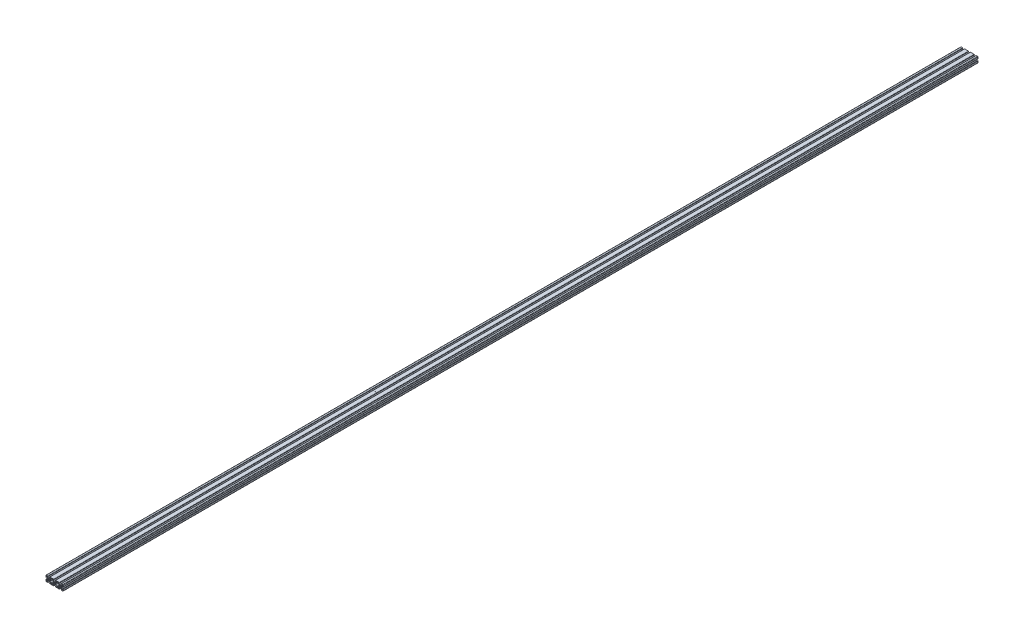
from build123d import *

# Parameters (mm, degrees)
SKETCH2_R      = 2.5
SKETCH2_R_2    = 2.500000001
EXTRUDE1_DEPTH = 4000


with BuildPart() as part:
    # Sketch2 → Extrude1 (new body)
    with BuildSketch(Plane.XY):
        with BuildLine():
            Line((-29.319999998, -10.360000001), (-31.428177133, -10.360000001))
            ThreePointArc((-31.428177133, -10.360000001), (-32.353740777, -9.741558146), (-32.136572877, -8.649781388))
            Line((-32.136572877, -8.649781388), (-29.108786522, -5.621995032))
            ThreePointArc((-29.108786522, -5.621995032), (-28.001435275, -4.721873879), (-26.611168365, -4.399999999))
            Line((-26.611168365, -4.399999999), (-23.423540193, -4.399999999))
            ThreePointArc((-23.423540193, -4.399999999), (-22.212951572, -4.640801047), (-21.186664095, -5.326544416))
            Line((-21.186664095, -5.326544416), (-17.863427125, -8.649781386))
            ThreePointArc((-17.863427125, -8.649781386), (-17.646259225, -9.741558144), (-18.571822869, -10.359999999))
            Line((-18.571822869, -10.359999999), (-20.680000002, -10.360000001))
            ThreePointArc((-20.680000002, -10.360000001), (-21.750000002, -11.430000001), (-20.680000002, -12.500000001))
            Line((-20.680000002, -12.500000001), (-4.320000002, -12.500000001))
            ThreePointArc((-4.320000002, -12.500000001), (-3.24968693, -11.403479825), (-4.371772704, -10.360000029))
            Line((-4.371772704, -10.360000001), (-6.428177131, -10.360000001))
            ThreePointArc((-6.428177131, -10.360000001), (-7.353740776, -9.741558146), (-7.136572876, -8.649781386))
            Line((-7.136572876, -8.649781386), (-3.813335906, -5.326544416))
            ThreePointArc((-3.813335906, -5.326544416), (-2.787048429, -4.640801048), (-1.576459809, -4.399999999))
            Line((-1.576459809, -4.399999999), (1.576459809, -4.399999999))
            ThreePointArc((1.576459809, -4.399999999), (2.787048429, -4.640801048), (3.813335906, -5.326544416))
            Line((3.813335906, -5.326544416), (7.136572876, -8.649781386))
            ThreePointArc((7.136572876, -8.649781386), (7.353740776, -9.741558146), (6.428177131, -10.360000001))
            Line((6.428177131, -10.360000001), (4.371772496, -10.360000001))
            ThreePointArc((4.371772496, -10.360000019), (3.249686927, -11.403479929), (4.320000002, -12.500000001))
            Line((4.320000002, -12.500000001), (20.671857829, -12.500000001))
            ThreePointArc((20.671857829, -12.500000001), (21.745921199, -11.32816463), (20.485180343, -10.359999998))
            Line((20.485180343, -10.359999998), (18.571822869, -10.359999999))
            ThreePointArc((18.571822869, -10.359999999), (17.646259225, -9.741558144), (17.863427125, -8.649781386))
            Line((17.863427125, -8.649781386), (21.186664094, -5.326544417))
            ThreePointArc((21.186664094, -5.326544417), (22.212951571, -4.640801048), (23.423540191, -4.4))
            Line((23.423540191, -4.4), (26.576459807, -4.4))
            ThreePointArc((26.576459807, -4.4), (27.787048427, -4.640801048), (28.813335904, -5.326544417))
            Line((28.813335904, -5.326544417), (32.136572872, -8.649781385))
            ThreePointArc((32.136572872, -8.649781385), (32.353740772, -9.741558143), (31.428177128, -10.359999998))
            Line((31.428177128, -10.359999998), (29.514819652, -10.359999998))
            ThreePointArc((29.514819652, -10.359999998), (28.254078799, -11.328164632), (29.32814217, -12.500000001))
            Line((29.32814217, -12.500000001), (35.535224212, -12.500000001))
            ThreePointArc((35.535224212, -12.500000001), (36.924530495, -11.924530496), (37.5, -10.535224214))
            Line((37.5, -10.535224214), (37.5, -4.32))
            ThreePointArc((37.5, -4.32), (36.43, -3.25), (35.36, -4.32))
            Line((35.36, -4.32), (35.36, -6.428177131))
            ThreePointArc((35.36, -6.428177131), (34.741558145, -7.353740775), (33.649781387, -7.136572875))
            Line((33.649781387, -7.136572875), (30.326544417, -3.813335905))
            ThreePointArc((30.326544417, -3.813335905), (29.640801048, -2.787048428), (29.4, -1.576459808))
            Line((29.4, -1.576459808), (29.4, 1.576459808))
            ThreePointArc((29.4, 1.576459808), (29.640801048, 2.787048428), (30.326544417, 3.813335905))
            Line((30.326544417, 3.813335905), (33.649781387, 7.136572875))
            ThreePointArc((33.649781387, 7.136572875), (34.741558145, 7.353740775), (35.36, 6.428177131))
            Line((35.36, 6.428177131), (35.36, 4.32))
            ThreePointArc((35.36, 4.32), (36.43, 3.25), (37.5, 4.32))
            Line((37.5, 4.32), (37.5, 9.215385711))
            Line((37.5, 9.215385711), (37.5, 10.535224213))
            ThreePointArc((37.5, 10.535224213), (36.924530495, 11.924530496), (35.535224212, 12.500000001))
            Line((35.535224212, 12.500000001), (29.514819654, 12.500000001))
            ThreePointArc((29.514819654, 12.500000001), (28.444819654, 11.430000001), (29.514819654, 10.360000001))
            Line((29.514819654, 10.360000001), (31.42817713, 10.360000001))
            ThreePointArc((31.42817713, 10.360000001), (32.353740774, 9.741558146), (32.136572875, 8.649781388))
            Line((32.136572875, 8.649781388), (28.813335904, 5.326544418))
            ThreePointArc((28.813335904, 5.326544418), (27.787048427, 4.640801049), (26.576459807, 4.400000001))
            Line((26.576459807, 4.400000001), (23.423540191, 4.400000001))
            ThreePointArc((23.423540191, 4.400000001), (22.212951571, 4.640801049), (21.186664094, 5.326544418))
            Line((21.186664094, 5.326544418), (17.863427125, 8.649781388))
            ThreePointArc((17.863427125, 8.649781388), (17.646259225, 9.741558147), (18.571822869, 10.360000001))
            Line((18.571822869, 10.360000001), (20.485180345, 10.360000001))
            ThreePointArc((20.485180345, 10.360000001), (21.555180345, 11.430000001), (20.485180345, 12.500000001))
            Line((20.485180345, 12.500000001), (4.320000001, 12.500000001))
            ThreePointArc((4.320000001, 12.500000001), (3.250000001, 11.430000001), (4.320000001, 10.360000001))
            Line((4.320000001, 10.360000001), (6.428177131, 10.360000001))
            ThreePointArc((6.428177131, 10.360000001), (7.353740776, 9.741558146), (7.136572876, 8.649781386))
            Line((7.136572876, 8.649781386), (3.813335906, 5.326544416))
            ThreePointArc((3.813335906, 5.326544416), (2.787048429, 4.640801048), (1.576459809, 4.399999999))
            Line((1.576459809, 4.399999999), (-1.576459809, 4.399999999))
            ThreePointArc((-1.576459809, 4.399999999), (-2.787048429, 4.640801048), (-3.813335906, 5.326544416))
            Line((-3.813335906, 5.326544416), (-7.136572876, 8.649781386))
            ThreePointArc((-7.136572876, 8.649781386), (-7.353740776, 9.741558146), (-6.428177131, 10.360000001))
            Line((-6.428177131, 10.360000001), (-4.32, 10.360000001))
            ThreePointArc((-4.32, 10.360000001), (-3.250000001, 11.430000001), (-4.320000001, 12.500000001))
            Line((-4.320000001, 12.500000001), (-20.680000002, 12.500000001))
            ThreePointArc((-20.680000002, 12.500000001), (-21.750000004, 11.429999998), (-20.680000002, 10.359999996))
            Line((-20.680000002, 10.359999996), (-18.571822869, 10.360000002))
            ThreePointArc((-18.571822869, 10.360000002), (-17.637276723, 9.719110041), (-17.898433453, 8.616425316))
            Line((-17.898433453, 8.616425316), (-21.6383227, 5.221217134))
            ThreePointArc((-21.6383227, 5.221217134), (-22.624955522, 4.612437324), (-23.764660556, 4.4))
            Line((-23.764660556, 4.4), (-26.576459811, 4.4))
            ThreePointArc((-26.576459811, 4.4), (-27.787048434, 4.640801049), (-28.813335912, 5.32654442))
            Line((-28.813335912, 5.32654442), (-32.136572876, 8.649781384))
            ThreePointArc((-32.136572876, 8.649781384), (-32.353740774, 9.741558142), (-31.428177131, 10.359999996))
            Line((-31.428177131, 10.359999996), (-29.319999998, 10.359999996))
            ThreePointArc((-29.319999998, 10.359999996), (-28.249999996, 11.429999998), (-29.319999998, 12.500000001))
            Line((-29.319999998, 12.500000001), (-35.535224212, 12.500000001))
            ThreePointArc((-35.535224212, 12.500000001), (-36.924530495, 11.924530496), (-37.5, 10.535224213))
            Line((-37.5, 10.535224213), (-37.5, 9.290954186))
            Line((-37.5, 9.290954186), (-37.5, 9.215385711))
            Line((-37.5, 9.215385711), (-37.5, 4.32))
            ThreePointArc((-37.5, 4.32), (-36.43, 3.25), (-35.36, 4.32))
            Line((-35.36, 4.32), (-35.36, 6.428177135))
            ThreePointArc((-35.36, 6.428177135), (-34.741558145, 7.353740779), (-33.649781386, 7.136572879))
            Line((-33.649781386, 7.136572879), (-30.326543072, 3.813334557))
            ThreePointArc((-30.326543072, 3.813334557), (-29.641357152, 2.788391999), (-29.399999998, 1.579370196))
            Line((-29.399999998, 1.579370196), (-29.399999998, -1.57645981))
            ThreePointArc((-29.399999998, -1.57645981), (-29.640801046, -2.78704843), (-30.326544415, -3.813335907))
            Line((-30.326544415, -3.813335907), (-33.649781387, -7.136572879))
            ThreePointArc((-33.649781387, -7.136572879), (-34.741558145, -7.353740779), (-35.36, -6.428177135))
            Line((-35.36, -6.428177135), (-35.36, -4.32))
            ThreePointArc((-35.36, -4.32), (-36.43, -3.25), (-37.5, -4.32))
            Line((-37.5, -4.32), (-37.5, -10.535224215))
            ThreePointArc((-37.5, -10.535224215), (-36.924530494, -11.924530497), (-35.53522421, -12.500000001))
            Line((-35.53522421, -12.500000001), (-29.319999998, -12.500000001))
            ThreePointArc((-29.319999998, -12.500000001), (-28.249999998, -11.430000001), (-29.319999998, -10.360000001))
        make_face()
        with Locations((-25, 0)):
            Circle(SKETCH2_R, mode=Mode.SUBTRACT)
        with BuildLine():
            ThreePointArc((-20.599999999, 1.576459808), (-20.35919895, 2.787048428), (-19.673455582, 3.813335905))
            Line((-19.673455582, 3.813335905), (-16.349967337, 7.1363216))
            ThreePointArc((-16.349967337, 7.1363216), (-15.658656636, 8.180575117), (-15.430103785, 9.411891278))
            Line((-15.430103785, 9.411891278), (-15.430103785, 9.597804878))
            ThreePointArc((-15.430103785, 9.597804878), (-15.206862003, 10.136758217), (-14.667908663, 10.36))
            Line((-14.667908663, 10.36), (-10.460981115, 10.36))
            ThreePointArc((-10.460981115, 10.36), (-9.903906578, 10.14715094), (-9.670608862, 9.598325888))
            Line((-9.670608862, 9.598325888), (-9.670608862, 9.411891278))
            ThreePointArc((-9.670608862, 9.411891278), (-9.42930698, 8.198784797), (-8.742137359, 7.170362781))
            Line((-8.742137359, 7.170362781), (-5.347574558, 3.775799981))
            ThreePointArc((-5.347574558, 3.775799981), (-4.66183119, 2.749512504), (-4.421030141, 1.538923884))
            Line((-4.421030141, 1.538923884), (-4.421030141, -1.613995732))
            ThreePointArc((-4.421030141, -1.613995732), (-4.66183119, -2.824584352), (-5.347574558, -3.850871829))
            Line((-5.347574558, -3.850871829), (-8.799493737, -7.302791007))
            ThreePointArc((-8.799493737, -7.302791007), (-9.486663358, -8.331213023), (-9.72796524, -9.544319504))
            Line((-9.72796524, -9.544319504), (-9.72796524, -9.655265042))
            ThreePointArc((-9.72796524, -9.655265042), (-9.951207023, -10.194218381), (-10.490160362, -10.417460164))
            Line((-10.490160362, -10.417460164), (-14.69708791, -10.417460164))
            ThreePointArc((-14.69708791, -10.417460164), (-15.198527228, -10.175674097), (-15.401822869, -9.657434024))
            Line((-15.401822869, -9.657434024), (-15.401822869, -9.35817713))
            ThreePointArc((-15.401822869, -9.35817713), (-15.64312475, -8.14507065), (-16.330294371, -7.116648635))
            Line((-16.330294371, -7.116648635), (-19.673455582, -3.813335905))
            ThreePointArc((-19.673455582, -3.813335905), (-20.35919895, -2.787048428), (-20.599999999, -1.576459808))
            Line((-20.599999999, -1.576459808), (-20.599999999, 1.576459808))
        make_face(mode=Mode.SUBTRACT)
        Circle(SKETCH2_R, mode=Mode.SUBTRACT)
        with BuildLine():
            Line((5.347574558, 3.775799981), (8.742137359, 7.170362781))
            ThreePointArc((8.742137359, 7.170362781), (9.42930698, 8.198784797), (9.670608862, 9.411891278))
            Line((9.670608862, 9.411891278), (9.670608862, 9.598325888))
            ThreePointArc((9.670608862, 9.598325888), (9.903906578, 10.14715094), (10.460981115, 10.36))
            Line((10.460981115, 10.36), (14.667908663, 10.36))
            ThreePointArc((14.667908663, 10.36), (15.206862003, 10.136758217), (15.430103785, 9.597804878))
            Line((15.430103785, 9.597804878), (15.430103785, 9.411891278))
            ThreePointArc((15.430103785, 9.411891278), (15.658656636, 8.180575117), (16.349967337, 7.1363216))
            Line((16.349967337, 7.1363216), (19.673455582, 3.813335905))
            ThreePointArc((19.673455582, 3.813335905), (20.35919895, 2.787048428), (20.599999999, 1.576459808))
            Line((20.599999999, 1.576459808), (20.599999999, -1.576459808))
            ThreePointArc((20.599999999, -1.576459808), (20.35919895, -2.787048428), (19.673455582, -3.813335905))
            Line((19.673455582, -3.813335905), (16.330294371, -7.116648635))
            ThreePointArc((16.330294371, -7.116648635), (15.64312475, -8.14507065), (15.401822869, -9.35817713))
            Line((15.401822869, -9.35817713), (15.401822869, -9.657434024))
            ThreePointArc((15.401822869, -9.657434024), (15.198527228, -10.175674097), (14.69708791, -10.417460164))
            Line((14.69708791, -10.417460164), (10.490160362, -10.417460164))
            ThreePointArc((10.490160362, -10.417460164), (9.951207023, -10.194218381), (9.72796524, -9.655265042))
            Line((9.72796524, -9.655265042), (9.72796524, -9.544319504))
            ThreePointArc((9.72796524, -9.544319504), (9.486663358, -8.331213023), (8.799493737, -7.302791007))
            Line((8.799493737, -7.302791007), (5.347574558, -3.850871829))
            ThreePointArc((5.347574558, -3.850871829), (4.66183119, -2.824584352), (4.421030141, -1.613995732))
            Line((4.421030141, -1.613995732), (4.421030141, 1.538923884))
            ThreePointArc((4.421030141, 1.538923884), (4.66183119, 2.749512504), (5.347574558, 3.775799981))
        make_face(mode=Mode.SUBTRACT)
        with Locations((24.999999999, 0)):
            Circle(SKETCH2_R_2, mode=Mode.SUBTRACT)
    extrude(amount=-EXTRUDE1_DEPTH)


solid = part.part
